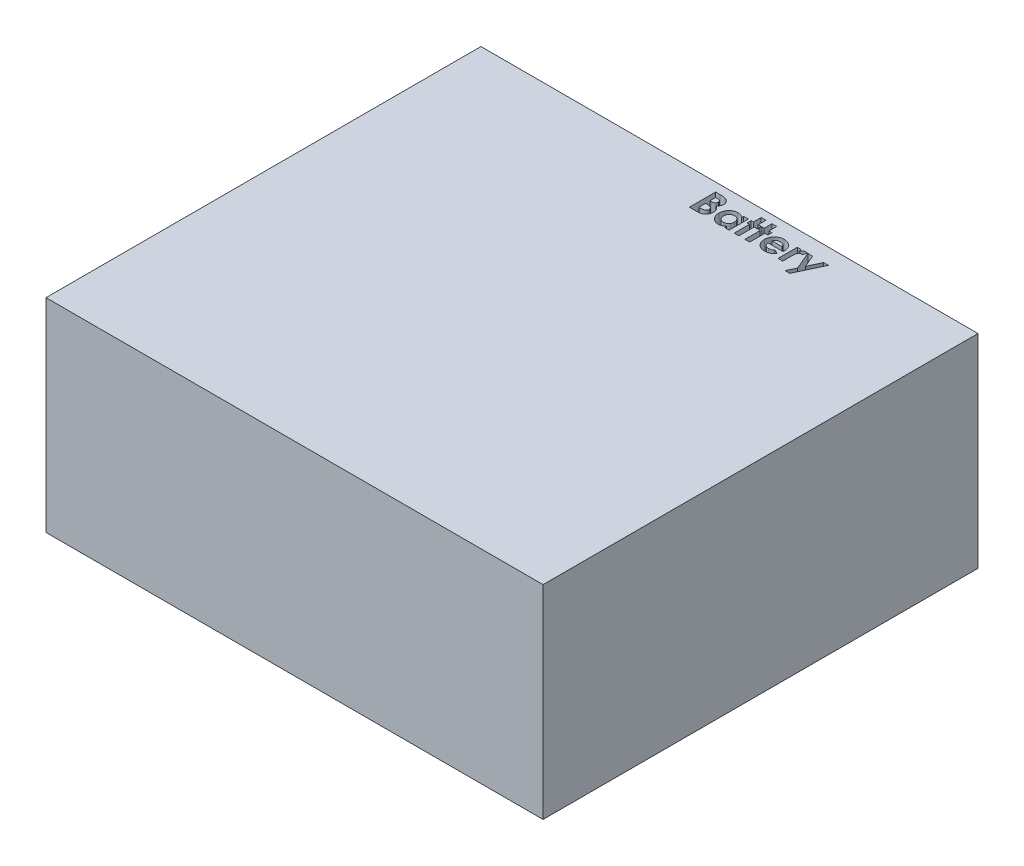
from build123d import *

# Parameters (mm, degrees)
SKETCH1_W           = 240
SKETCH1_H           = 210
BOSS_EXTRUDE1_DEPTH = 98.2
CUT_EXTRUDE1_DEPTH  = 101.6


with BuildPart() as part:
    # Sketch1 → Boss-Extrude1 (new body)
    with BuildSketch(Plane(origin=(0, 0, 0), x_dir=(1, 0, 0), z_dir=(0, 1, 0))):
        with Locations((120, 105)):
            Rectangle(SKETCH1_W, SKETCH1_H)
    extrude(amount=BOSS_EXTRUDE1_DEPTH)

    # Sketch2 → Cut-Extrude1 (cut)
    with BuildSketch(Plane(origin=(0, 98.2, 0), x_dir=(1, 0, 0), z_dir=(0, 1, 0))):
        with BuildLine():
            Line((117.496663444, 193.133578888), (117.496663444, 205.833578888))
            Line((117.496663444, 205.833578888), (119.531919854, 205.833578888))
            add(Edge.make_bspline(
                [(119.531919854, 205.833578888), (119.674400529, 205.833595149), (119.950097933, 205.833626612), (120.347857336, 205.819658608), (120.716745592, 205.80158943), (121.055588753, 205.781374221), (121.364963555, 205.746539377), (121.644399542, 205.709827257), (121.89445503, 205.665554702), (122.04905075, 205.62584085), (122.121783636, 205.607156612)],
                knots=[0, 0, 0, 0, 1.311965854, 2.538629056, 3.664479157, 4.713267157, 5.663616078, 6.530575999, 7.308677837, 8, 8, 8, 8], degree=3))
            add(Edge.make_bspline(
                [(122.121783636, 205.607156612), (122.217289299, 205.580802163), (122.404702071, 205.529086273), (122.673136967, 205.424643797), (122.927784911, 205.30854858), (123.168334985, 205.176105652), (123.393310114, 205.025716053), (123.601855317, 204.856186249), (123.798468398, 204.674321156), (123.976168075, 204.475052247), (124.136779304, 204.264487733), (124.276321667, 204.042682786), (124.397566095, 203.81302895), (124.494593395, 203.572636183), (124.567701643, 203.32261156), (124.62117271, 203.064022723), (124.655829203, 202.796051434), (124.659103787, 202.613741808), (124.660766008, 202.52119908)],
                knots=[0, 0, 0, 0, 1.099996261, 2.158545794, 3.195537121, 4.207578794, 5.205712374, 6.197378256, 7.190519799, 8.17788031, 9.159561366, 10.129234751, 11.085776129, 12.040971148, 13.00380137, 13.975669004, 14.972423361, 16, 16, 16, 16], degree=3))
            add(Edge.make_bspline(
                [(124.660766008, 202.52119908), (124.656419793, 202.402305966), (124.647864803, 202.168279478), (124.593214946, 201.824536907), (124.49073795, 201.499650771), (124.356649293, 201.18763354), (124.17433064, 200.889649041), (123.942821212, 200.605838956), (123.665870704, 200.327464349), (123.453434375, 200.160597549), (123.342937482, 200.073803247)],
                knots=[0, 0, 0, 0, 0.986156485, 1.941127874, 2.875419072, 3.804401753, 4.751181392, 5.761612777, 6.835722519, 8, 8, 8, 8], degree=3))
            add(Edge.make_bspline(
                [(123.342937482, 200.073803247), (123.432478863, 200.028093148), (123.608044739, 199.938468291), (123.857296704, 199.791151781), (124.088076815, 199.634461989), (124.301419821, 199.471551577), (124.492850608, 199.295514535), (124.670273675, 199.116494361), (124.824935888, 198.924233942), (124.9632395, 198.725585807), (125.083450752, 198.517673507), (125.188141497, 198.300848159), (125.276570013, 198.074369041), (125.351453568, 197.839388747), (125.407301744, 197.595099056), (125.443715942, 197.3414126), (125.471596928, 197.079194578), (125.473765806, 196.90057821), (125.474868572, 196.809760779)],
                knots=[0, 0, 0, 0, 1.164658916, 2.283573913, 3.35186032, 4.395461096, 5.390182219, 6.362969632, 7.312859996, 8.245001507, 9.165155236, 10.092416118, 11.032087915, 11.979892451, 12.947605196, 13.931445124, 14.948243989, 16, 16, 16, 16], degree=3))
            add(Edge.make_bspline(
                [(125.474868572, 196.809760779), (125.46771236, 196.636304679), (125.453589605, 196.293989761), (125.350330909, 195.791392844), (125.171313142, 195.314885381), (124.930929194, 194.866361217), (124.634729921, 194.45880439), (124.294185697, 194.101788147), (123.912725021, 193.799581824), (123.560781443, 193.595616), (123.256377963, 193.458735859), (123.004246248, 193.374107924), (122.733462131, 193.295708733), (122.439065496, 193.240655202), (122.126393353, 193.190264157), (121.79239713, 193.159151682), (121.437701059, 193.138067524), (121.194080464, 193.135105349), (121.068538444, 193.133578888)],
                knots=[0, 0, 0, 0, 1.284142165, 2.534249414, 3.780121997, 5.041676246, 6.291546858, 7.49970053, 8.684500223, 9.883330709, 10.50184324, 11.153274765, 11.851151195, 12.587658647, 13.369265475, 14.195992086, 15.070362669, 16, 16, 16, 16], degree=3))
            Line((121.068538444, 193.133578888), (117.496663444, 193.133578888))
        make_face()
        with BuildLine():
            Line((119.776150623, 203.554091709), (119.776150623, 200.786142991))
            Line((119.776150623, 200.786142991), (120.381639405, 200.786142991))
            add(Edge.make_bspline(
                [(120.381639405, 200.786142991), (120.463930771, 200.786860602), (120.622789272, 200.788245909), (120.852243526, 200.806088172), (121.065598927, 200.836528181), (121.262046263, 200.878999652), (121.443415514, 200.932932227), (121.608548039, 200.99782473), (121.756717782, 201.077000637), (121.928856753, 201.194936645), (122.110820059, 201.36848476), (122.271000311, 201.61921097), (122.365345409, 201.907545157), (122.375852909, 202.110900752), (122.381278828, 202.215910619)],
                knots=[0, 0, 0, 0, 1.065314748, 2.056525647, 2.977365736, 3.853934255, 4.656397591, 5.425096493, 6.14721249, 6.826394842, 8.123232004, 9.372140726, 10.643011755, 12, 12, 12, 12], degree=3))
            add(Edge.make_bspline(
                [(122.381278828, 202.215910619), (122.376937099, 202.314269806), (122.368542541, 202.504443342), (122.273549156, 202.771463924), (122.126005651, 203.008098807), (121.951809805, 203.170056034), (121.787770566, 203.280668044), (121.647310104, 203.353501343), (121.4931442, 203.418700968), (121.322288366, 203.46855419), (121.135718284, 203.505962292), (120.934340229, 203.533434064), (120.717806753, 203.55213252), (120.56824662, 203.553424638), (120.491034437, 203.554091709)],
                knots=[0, 0, 0, 0, 1.347982417, 2.606269829, 3.849316587, 5.153353503, 5.842674298, 6.568177932, 7.326619318, 8.142485038, 9.012069166, 9.942760135, 10.937925643, 12, 12, 12, 12], degree=3))
            Line((120.491034437, 203.554091709), (119.776150623, 203.554091709))
        make_face(mode=Mode.SUBTRACT)
        with BuildLine():
            Line((119.776150623, 198.669476324), (119.776150623, 195.413066067))
            Line((119.776150623, 195.413066067), (120.432520815, 195.413066067))
            add(Edge.make_bspline(
                [(120.432520815, 195.413066067), (120.562286038, 195.413807411), (120.811775872, 195.415232738), (121.169169616, 195.432454067), (121.494129878, 195.463492479), (121.785795635, 195.502241436), (122.04461363, 195.554740211), (122.269708995, 195.621485677), (122.464168621, 195.694917314), (122.626826519, 195.785614105), (122.759708704, 195.891162678), (122.879620943, 195.999035855), (122.977389911, 196.123477757), (123.054746543, 196.259146436), (123.121698571, 196.402671786), (123.162079307, 196.55965842), (123.192823782, 196.72545363), (123.194515732, 196.840130591), (123.195381392, 196.898803247)],
                knots=[0, 0, 0, 0, 1.753078804, 3.370512758, 4.83203934, 6.162291463, 7.344201807, 8.395507345, 9.331626367, 10.147333109, 10.898971645, 11.62040215, 12.321813352, 13.025280112, 13.727906689, 14.453419512, 15.208716525, 16, 16, 16, 16], degree=3))
            add(Edge.make_bspline(
                [(123.195381392, 196.898803247), (123.193472364, 196.965896352), (123.18975409, 197.09657567), (123.159386902, 197.287577441), (123.104199802, 197.465890267), (123.034688957, 197.636073848), (122.937960923, 197.792035018), (122.82300296, 197.939171003), (122.684104393, 198.072499324), (122.527904852, 198.200084175), (122.345713552, 198.311791625), (122.137445014, 198.408717625), (121.901967811, 198.48966665), (121.638552526, 198.554118317), (121.348353951, 198.608817556), (121.029253957, 198.64147904), (120.683910118, 198.665770821), (120.44444308, 198.66821309), (120.320581713, 198.669476324)],
                knots=[0, 0, 0, 0, 0.845221588, 1.646264278, 2.427170338, 3.19324141, 3.95557735, 4.731569926, 5.540061037, 6.376114724, 7.268642756, 8.224665384, 9.265483498, 10.400594375, 11.639216012, 12.983232105, 14.439614077, 16, 16, 16, 16], degree=3))
            Line((120.320581713, 198.669476324), (119.776150623, 198.669476324))
        make_face(mode=Mode.SUBTRACT)
        with BuildLine():
            Line((134.429996777, 202.414348119), (136.709483956, 202.414348119))
            Line((136.709483956, 202.414348119), (136.709483956, 193.133578888))
            Line((136.709483956, 193.133578888), (134.429996777, 193.133578888))
            Line((134.429996777, 193.133578888), (134.429996777, 194.146118952))
            add(Edge.make_bspline(
                [(134.429996777, 194.146118952), (134.317049027, 194.047559383), (134.097839749, 193.856274724), (133.75243686, 193.608078015), (133.406024663, 193.403347807), (133.05693864, 193.240291361), (132.699813483, 193.119890959), (132.332078035, 193.032718256), (131.948436514, 192.98131038), (131.687642294, 192.974312348), (131.555197097, 192.970758375)],
                knots=[0, 0, 0, 0, 1.129196829, 2.191548051, 3.199897424, 4.157751732, 5.089409408, 6.034969131, 7.002052659, 8, 8, 8, 8], degree=3))
            add(Edge.make_bspline(
                [(131.555197097, 192.970758375), (131.406521477, 192.974103112), (131.112730025, 192.9807125), (130.681623686, 193.050286981), (130.265347656, 193.156786231), (129.864239836, 193.307495981), (129.479030005, 193.502786272), (129.10677014, 193.737561706), (128.753841909, 194.020064306), (128.417307305, 194.338070904), (128.10917824, 194.687880424), (127.839808903, 195.064637559), (127.612750572, 195.462998839), (127.42673383, 195.881643515), (127.280407641, 196.320264324), (127.176098007, 196.780252439), (127.114555203, 197.261772143), (127.106937938, 197.589764508), (127.1030737, 197.75615501)],
                knots=[0, 0, 0, 0, 0.980476535, 1.937477201, 2.874147792, 3.812856188, 4.758993464, 5.720109578, 6.712210464, 7.737600662, 8.772720504, 9.783789959, 10.789002326, 11.793715968, 12.802552247, 13.835794126, 14.902098527, 16, 16, 16, 16], degree=3))
            add(Edge.make_bspline(
                [(127.1030737, 197.75615501), (127.107129232, 197.928452593), (127.115084611, 198.2664335), (127.173277727, 198.762404411), (127.275662456, 199.233797893), (127.415271394, 199.681266894), (127.59485405, 200.104888719), (127.813573727, 200.505357396), (128.074405899, 200.881626165), (128.374968739, 201.227290666), (128.699502785, 201.544108877), (129.046696841, 201.819924254), (129.411121551, 202.054242252), (129.793164183, 202.245536668), (130.192770176, 202.393359312), (130.608361893, 202.501429736), (131.041784268, 202.566275786), (131.337035103, 202.573507529), (131.486507194, 202.577168632)],
                knots=[0, 0, 0, 0, 1.136281865, 2.228943489, 3.287578264, 4.313574083, 5.316051562, 6.317280042, 7.318008486, 8.329309503, 9.333984563, 10.305318864, 11.248632312, 12.186624717, 13.117503092, 14.05354244, 15.014596925, 16, 16, 16, 16], degree=3))
            add(Edge.make_bspline(
                [(131.486507194, 202.577168632), (131.624966781, 202.574292105), (131.898928398, 202.568600495), (132.301612501, 202.506800503), (132.692158002, 202.413332405), (133.068434456, 202.280157189), (133.433528207, 202.111996386), (133.781159412, 201.901278365), (134.118932818, 201.656859511), (134.325027704, 201.465963208), (134.429996777, 201.368735138)],
                knots=[0, 0, 0, 0, 1.017011718, 2.012299608, 2.98747302, 3.965332399, 4.941441765, 5.936729654, 6.94912688, 8, 8, 8, 8], degree=3))
            Line((134.429996777, 201.368735138), (134.429996777, 202.414348119))
        make_face()
        with BuildLine():
            add(Edge.make_bspline(
                [(131.96479245, 200.460501965), (131.873961605, 200.457714961), (131.695939081, 200.452252616), (131.434132596, 200.419396226), (131.183924134, 200.361501803), (130.947098164, 200.275975226), (130.720125109, 200.171791395), (130.506451588, 200.04130286), (130.304314091, 199.887068184), (130.114901408, 199.712821388), (129.94222384, 199.5212923), (129.793365699, 199.312292568), (129.666860327, 199.091453547), (129.559869661, 198.858111249), (129.483288619, 198.609504514), (129.422636464, 198.348869761), (129.391161923, 198.074077735), (129.385456581, 197.886815474), (129.38256088, 197.791771997)],
                knots=[0, 0, 0, 0, 1.04836806, 2.054732945, 3.03993516, 4.00574415, 4.955904794, 5.917688631, 6.888591924, 7.88601754, 8.884115178, 9.859153345, 10.841239365, 11.818093293, 12.814750328, 13.83810466, 14.90274714, 16, 16, 16, 16], degree=3))
            add(Edge.make_bspline(
                [(129.38256088, 197.791771997), (129.385412348, 197.69586642), (129.391031134, 197.506885593), (129.423145377, 197.229775598), (129.481615016, 196.965333583), (129.566920015, 196.715697381), (129.671097206, 196.477498575), (129.797904276, 196.251836473), (129.95366455, 196.042701065), (130.126493489, 195.845143505), (130.319791942, 195.66873227), (130.523073216, 195.512095291), (130.739113969, 195.38103723), (130.965570315, 195.275115277), (131.201679989, 195.188797788), (131.450403092, 195.13163098), (131.709303066, 195.095085321), (131.885802016, 195.0899961), (131.974968732, 195.087425042)],
                knots=[0, 0, 0, 0, 1.099136573, 2.165835871, 3.191374663, 4.196217796, 5.183857741, 6.167377911, 7.154730987, 8.166690795, 9.170734848, 10.148332609, 11.103258353, 12.059567475, 13.009337315, 13.978056681, 14.978520572, 16, 16, 16, 16], degree=3))
            add(Edge.make_bspline(
                [(131.974968732, 195.087425042), (132.067491407, 195.09022767), (132.248886148, 195.095722345), (132.514963873, 195.128278885), (132.768533531, 195.186385583), (133.008540136, 195.272401819), (133.238649561, 195.375837817), (133.456785274, 195.503776506), (133.660580174, 195.657657255), (133.851066388, 195.833479248), (134.025610284, 196.026572286), (134.176527016, 196.238312717), (134.307981011, 196.461928503), (134.41136353, 196.702706734), (134.493463748, 196.956434916), (134.552368761, 197.224687741), (134.584409672, 197.507754416), (134.589979317, 197.700958452), (134.59281729, 197.799404209)],
                knots=[0, 0, 0, 0, 1.050008698, 2.058587853, 3.036635738, 3.995319155, 4.947022481, 5.895997462, 6.858296291, 7.838991643, 8.833936038, 9.806048392, 10.784806122, 11.771666913, 12.772873988, 13.80724452, 14.882696879, 16, 16, 16, 16], degree=3))
            add(Edge.make_bspline(
                [(134.59281729, 197.799404209), (134.590014581, 197.896156745), (134.584540077, 198.085142554), (134.552230577, 198.36229893), (134.492907372, 198.625284494), (134.412496912, 198.874582647), (134.307275186, 199.109623371), (134.175721729, 199.327800625), (134.026460467, 199.536673433), (133.849984118, 199.724549959), (133.660529811, 199.899098865), (133.453737776, 200.048326148), (133.236123087, 200.176934362), (133.006348715, 200.282526665), (132.762287051, 200.359929826), (132.50828406, 200.419860262), (132.240376766, 200.452232896), (132.058152963, 200.457700628), (131.96479245, 200.460501965)],
                knots=[0, 0, 0, 0, 1.106611376, 2.161533483, 3.185006901, 4.184773755, 5.152708835, 6.122342771, 7.094156588, 8.082475533, 9.064254463, 10.03606828, 10.992420271, 11.951521816, 12.920622147, 13.915721683, 14.932141191, 16, 16, 16, 16], degree=3))
        make_face(mode=Mode.SUBTRACT)
        Polygon((139.151791649, 206.159219914), (141.431278828, 206.159219914), (141.431278828, 202.414348119), (142.896663444, 202.414348119), (142.896663444, 200.460501965), (141.431278828, 200.460501965), (141.431278828, 193.133578888), (139.151791649, 193.133578888), (139.151791649, 200.460501965), (138.012048059, 200.460501965), (138.012048059, 202.414348119), (139.151791649, 202.414348119), align=None)
        Polygon((144.362048059, 206.159219914), (146.641535239, 206.159219914), (146.641535239, 202.414348119), (148.106919854, 202.414348119), (148.106919854, 200.460501965), (146.641535239, 200.460501965), (146.641535239, 193.133578888), (144.362048059, 193.133578888), (144.362048059, 200.460501965), (143.222304469, 200.460501965), (143.222304469, 202.414348119), (144.362048059, 202.414348119), align=None)
        with BuildLine():
            Line((158.682620976, 197.204091709), (151.36333011, 197.204091709))
            add(Edge.make_bspline(
                [(151.36333011, 197.204091709), (151.378253553, 197.119045701), (151.407579296, 196.951923587), (151.47126119, 196.709164214), (151.552528837, 196.480391878), (151.649922994, 196.265300767), (151.761801596, 196.06275378), (151.892298717, 195.873700938), (152.039759119, 195.698309228), (152.203330225, 195.53734092), (152.380285603, 195.393109828), (152.569767084, 195.266754273), (152.771970201, 195.163150447), (152.984576771, 195.075823173), (153.209175455, 195.006651125), (153.446096806, 194.958944479), (153.69471278, 194.930763989), (153.864077577, 194.926688003), (153.950649822, 194.924604529)],
                knots=[0, 0, 0, 0, 1.091296461, 2.144483647, 3.168565212, 4.157007626, 5.126487748, 6.090021542, 7.05641414, 8.019231907, 8.98705074, 9.938580405, 10.892824166, 11.854447369, 12.841318655, 13.858982407, 14.905600794, 16, 16, 16, 16], degree=3))
            add(Edge.make_bspline(
                [(153.950649822, 194.924604529), (154.055148398, 194.927363392), (154.260936869, 194.932796407), (154.562418512, 194.980979175), (154.853995176, 195.05375713), (155.13290752, 195.161984057), (155.402386304, 195.296707556), (155.657995081, 195.464556458), (155.904158238, 195.660625671), (156.054346773, 195.811755745), (156.130918251, 195.888807253)],
                knots=[0, 0, 0, 0, 1.021034703, 2.010718019, 2.977989445, 3.954245119, 4.929443971, 5.918328161, 6.938689359, 8, 8, 8, 8], degree=3))
            Line((156.130918251, 195.888807253), (158.038971136, 194.98057408))
            add(Edge.make_bspline(
                [(158.038971136, 194.98057408), (157.978897204, 194.897561127), (157.859862919, 194.733074013), (157.665543441, 194.501598161), (157.462758693, 194.285621801), (157.251357438, 194.086565442), (157.031071566, 193.904996315), (156.802513859, 193.738702582), (156.562344039, 193.592149161), (156.315364259, 193.458245888), (156.05646899, 193.343451232), (155.78637471, 193.245558402), (155.506225418, 193.157064117), (155.212483435, 193.089636319), (154.907594748, 193.036261024), (154.590830003, 192.998357494), (154.262230949, 192.974946299), (154.038884086, 192.972170931), (153.925209117, 192.970758375)],
                knots=[0, 0, 0, 0, 1.028154879, 2.037251081, 3.030720504, 4.000128189, 4.949298328, 5.894184978, 6.834267904, 7.770992897, 8.712077017, 9.673380525, 10.653304757, 11.658697181, 12.695551717, 13.758623199, 14.859225354, 16, 16, 16, 16], degree=3))
            add(Edge.make_bspline(
                [(153.925209117, 192.970758375), (153.750322043, 192.974323796), (153.40781579, 192.981306469), (152.906838479, 193.046115659), (152.431048985, 193.153576282), (151.979103843, 193.299652494), (151.552956663, 193.492518857), (151.152396543, 193.728410418), (150.773421314, 194.002804662), (150.427610786, 194.321460397), (150.112567192, 194.66829822), (149.835852487, 195.040778357), (149.604301563, 195.43629843), (149.414147287, 195.852240806), (149.266352778, 196.289670133), (149.159801509, 196.748777297), (149.094484305, 197.229343019), (149.087429723, 197.556661921), (149.083842931, 197.723082093)],
                knots=[0, 0, 0, 0, 1.103565453, 2.161269334, 3.182010356, 4.179077853, 5.15417608, 6.128274628, 7.109042802, 8.101804412, 9.090965879, 10.063106201, 11.02526161, 11.978650795, 12.945248442, 13.93468508, 14.949922959, 16, 16, 16, 16], degree=3))
            add(Edge.make_bspline(
                [(149.083842931, 197.723082093), (149.087465024, 197.893731215), (149.094591331, 198.229475699), (149.159239129, 198.721137903), (149.266647355, 199.190250147), (149.414874196, 199.637458446), (149.602143808, 200.064161477), (149.836640821, 200.4666261), (150.112429874, 200.846253476), (150.426338529, 201.201267672), (150.773614018, 201.52170677), (151.142627034, 201.807282043), (151.537523818, 202.045242316), (151.953837746, 202.23751407), (152.388905924, 202.393730016), (152.847757133, 202.497678681), (153.326900214, 202.567473988), (153.654431874, 202.5739017), (153.820902226, 202.577168632)],
                knots=[0, 0, 0, 0, 1.079208495, 2.12329425, 3.130605359, 4.119693003, 5.099659317, 6.073216462, 7.060498243, 8.06384408, 9.066070512, 10.045757761, 11.010926815, 11.975797609, 12.942977511, 13.929384301, 14.947594487, 16, 16, 16, 16], degree=3))
            add(Edge.make_bspline(
                [(153.820902226, 202.577168632), (153.996627127, 202.573547895), (154.34164486, 202.566438953), (154.846111324, 202.502155999), (155.325060003, 202.394040094), (155.780531487, 202.249226976), (156.206709219, 202.051488606), (156.612957615, 201.821401962), (156.989532536, 201.541076477), (157.340447868, 201.223980142), (157.657220673, 200.872172746), (157.934115203, 200.490002164), (158.169718369, 200.081198155), (158.360677073, 199.644102932), (158.508319824, 199.180028698), (158.614969725, 198.689578145), (158.679788715, 198.170885833), (158.686712027, 197.81570748), (158.690253187, 197.634039625)],
                knots=[0, 0, 0, 0, 1.080001299, 2.120471247, 3.119684163, 4.095710327, 5.052285597, 6.002875087, 6.961153713, 7.931888285, 8.906493152, 9.865905668, 10.82813294, 11.801621613, 12.7925306, 13.817193356, 14.883530496, 16, 16, 16, 16], degree=3))
            Line((158.690253187, 197.634039625), (158.682620976, 197.204091709))
        make_face()
        with BuildLine():
            add(Edge.make_bspline(
                [(156.410766008, 198.99511735), (156.367750691, 199.111198266), (156.282225034, 199.341997368), (156.089026136, 199.660443812), (155.83265738, 199.936231366), (155.534482125, 200.180388274), (155.193798226, 200.378561272), (154.821341228, 200.522044959), (154.421818917, 200.608079577), (154.146969096, 200.618169927), (154.006619373, 200.623322478)],
                knots=[0, 0, 0, 0, 0.954238005, 1.897273737, 2.851915805, 3.847685534, 4.862635127, 5.880135777, 6.917509367, 8, 8, 8, 8], degree=3))
            add(Edge.make_bspline(
                [(154.006619373, 200.623322478), (153.853334624, 200.618372825), (153.553694858, 200.608697285), (153.121484896, 200.505794363), (152.713792053, 200.352214825), (152.47343946, 200.193871061), (152.35297354, 200.114508375)],
                knots=[0, 0, 0, 0, 1.044195649, 2.041185066, 3.018232172, 4, 4, 4, 4], degree=3))
            add(Edge.make_bspline(
                [(152.35297354, 200.114508375), (152.277811803, 200.054064016), (152.117570822, 199.925199731), (151.909465398, 199.668127717), (151.704479824, 199.356871217), (151.587934223, 199.120449916), (151.526150623, 198.99511735)],
                knots=[0, 0, 0, 0, 0.82159062, 1.751589201, 2.808063854, 4, 4, 4, 4], degree=3))
            Line((151.526150623, 198.99511735), (156.410766008, 198.99511735))
        make_face(mode=Mode.SUBTRACT)
        with BuildLine():
            Line((160.318458315, 202.414348119), (162.272304469, 202.414348119))
            Line((162.272304469, 202.414348119), (162.272304469, 201.272060459))
            add(Edge.make_bspline(
                [(162.272304469, 201.272060459), (162.327575026, 201.373575877), (162.435603622, 201.571991974), (162.634061214, 201.838326292), (162.862057333, 202.062625624), (163.111399374, 202.249581394), (163.382843045, 202.395295059), (163.669119566, 202.499134415), (163.967779848, 202.566615608), (164.171515767, 202.573625628), (164.274487963, 202.577168632)],
                knots=[0, 0, 0, 0, 1.09866127, 2.147379032, 3.14564304, 4.131443017, 5.102343063, 6.064490016, 7.021754664, 8, 8, 8, 8], degree=3))
            add(Edge.make_bspline(
                [(164.274487963, 202.577168632), (164.349258626, 202.573667404), (164.501518395, 202.566537653), (164.733583708, 202.525092306), (164.968997316, 202.450151237), (165.123919757, 202.382676765), (165.2030737, 202.348202285)],
                knots=[0, 0, 0, 0, 0.931404136, 1.896671404, 2.925354185, 4, 4, 4, 4], degree=3))
            Line((165.2030737, 202.348202285), (164.495822097, 200.417252766))
            add(Edge.make_bspline(
                [(164.495822097, 200.417252766), (164.432603904, 200.447796741), (164.313778036, 200.505207655), (164.141263507, 200.572958449), (163.98469942, 200.614296671), (163.885440662, 200.620464697), (163.839451905, 200.623322478)],
                knots=[0, 0, 0, 0, 1.214386998, 2.282580073, 3.20428172, 4, 4, 4, 4], degree=3))
            add(Edge.make_bspline(
                [(163.839451905, 200.623322478), (163.796029575, 200.621428761), (163.71061037, 200.617703494), (163.584534014, 200.585779219), (163.46579634, 200.530726796), (163.348675387, 200.46019918), (163.242410699, 200.362160518), (163.136211648, 200.248663359), (163.042623359, 200.10853602), (162.943860571, 199.952567176), (162.859767589, 199.761661451), (162.787660446, 199.533759356), (162.723412403, 199.266223908), (162.679200978, 198.957634623), (162.63646886, 198.610977637), (162.611033655, 198.22370853), (162.592076474, 197.797051884), (162.590917369, 197.499230147), (162.590313283, 197.344015587)],
                knots=[0, 0, 0, 0, 0.544232178, 1.070598461, 1.618251235, 2.182094276, 2.777567932, 3.425210017, 4.127676488, 4.886675562, 5.738955394, 6.734782583, 7.883056018, 9.186093582, 10.642914445, 12.264202625, 14.053029461, 16, 16, 16, 16], degree=3))
            Line((162.590313283, 197.344015587), (162.597945495, 196.891171035))
            Line((162.597945495, 196.891171035), (162.597945495, 193.133578888))
            Line((162.597945495, 193.133578888), (160.318458315, 193.133578888))
            Line((160.318458315, 193.133578888), (160.318458315, 202.414348119))
        make_face()
        Polygon((165.442216328, 202.414348119), (167.724247578, 202.414348119), (170.258141809, 196.443414625), (173.061707514, 202.414348119), (175.379355751, 202.414348119), (169.413510399, 189.714348119), (167.095862162, 189.714348119), (169.057340527, 193.88916783), align=None)
    extrude(amount=-CUT_EXTRUDE1_DEPTH, mode=Mode.SUBTRACT)


with BuildPart() as cut_extrude1_piece_1:
    # of the separate pieces the step leaves, piece 1, a body of its own (cut_extrude1_pieces)
    add(part.part.solids().sort_by_distance((0, 0, 0))[0])


with BuildPart() as cut_extrude1_piece_2:
    # of the separate pieces the step leaves, piece 2, a body of its own (cut_extrude1_pieces)
    add(part.part.solids().sort_by_distance((129.38256088, 0, -197.791771997))[0])


with BuildPart() as cut_extrude1_piece_3:
    # of the separate pieces the step leaves, piece 3, a body of its own (cut_extrude1_pieces)
    add(part.part.solids().sort_by_distance((120.320581713, 0, -198.669476324))[0])


with BuildPart() as cut_extrude1_piece_4:
    # of the separate pieces the step leaves, piece 4, a body of its own (cut_extrude1_pieces)
    add(part.part.solids().sort_by_distance((120.491034437, 0, -203.554091709))[0])


with BuildPart() as cut_extrude1_piece_5:
    # of the separate pieces the step leaves, piece 5, a body of its own (cut_extrude1_pieces)
    add(part.part.solids().sort_by_distance((154.006619373, 0, -200.623322478))[0])


solid = Compound([cut_extrude1_piece_1.part, cut_extrude1_piece_2.part, cut_extrude1_piece_3.part, cut_extrude1_piece_4.part, cut_extrude1_piece_5.part])
